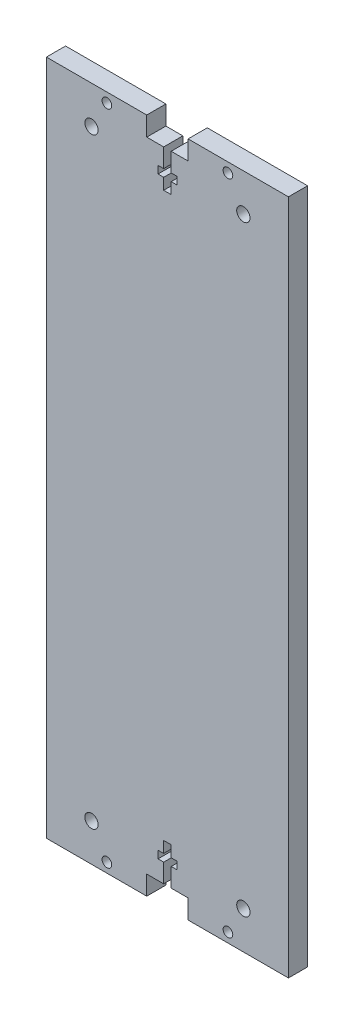
from build123d import *

# Parameters (mm, degrees)
SKETCH1_R           = 2.2479
SKETCH1_R_2         = 1.63195
BOSS_EXTRUDE1_DEPTH = 6.477


with BuildPart() as part:
    # Sketch1 → Boss-Extrude1 (new body)
    with BuildSketch(Plane.XY):
        Polygon((-6.985, -107.823), (-1.27, -107.823), (-1.27, -101.473), (-3.175, -101.473), (-3.175, -98.933), (-1.27, -98.933), (-1.27, -95.123), (1.27, -95.123), (1.27, -98.933), (3.175, -98.933), (3.175, -101.473), (1.27, -101.473), (1.27, -107.823), (6.985, -107.823), (6.985, -114.3), (40.894, -114.3), (40.894, 114.3), (6.985, 114.3), (6.985, 107.823), (1.27, 107.823), (1.27, 101.473), (3.175, 101.473), (3.175, 98.933), (1.27, 98.933), (1.27, 95.123), (-1.27, 95.123), (-1.27, 98.933), (-3.175, 98.933), (-3.175, 101.473), (-1.27, 101.473), (-1.27, 107.823), (-6.985, 107.823), (-6.985, 114.3), (-40.894, 114.3), (-40.894, -114.3), (-6.985, -114.3), align=None)
        with Locations((-25.654, -101.6)):
            Circle(SKETCH1_R, mode=Mode.SUBTRACT)
        with Locations((-20.447, -111.0615)):
            Circle(SKETCH1_R_2, mode=Mode.SUBTRACT)
        with Locations((20.447, -111.0615)):
            Circle(SKETCH1_R_2, mode=Mode.SUBTRACT)
        with Locations((25.654, -101.6)):
            Circle(SKETCH1_R, mode=Mode.SUBTRACT)
        with Locations((-25.654, 101.6)):
            Circle(SKETCH1_R, mode=Mode.SUBTRACT)
        with Locations((-20.447, 111.0615)):
            Circle(SKETCH1_R_2, mode=Mode.SUBTRACT)
        with Locations((20.447, 111.0615)):
            Circle(SKETCH1_R_2, mode=Mode.SUBTRACT)
        with Locations((25.654, 101.6)):
            Circle(SKETCH1_R, mode=Mode.SUBTRACT)
    extrude(amount=BOSS_EXTRUDE1_DEPTH)


solid = part.part
